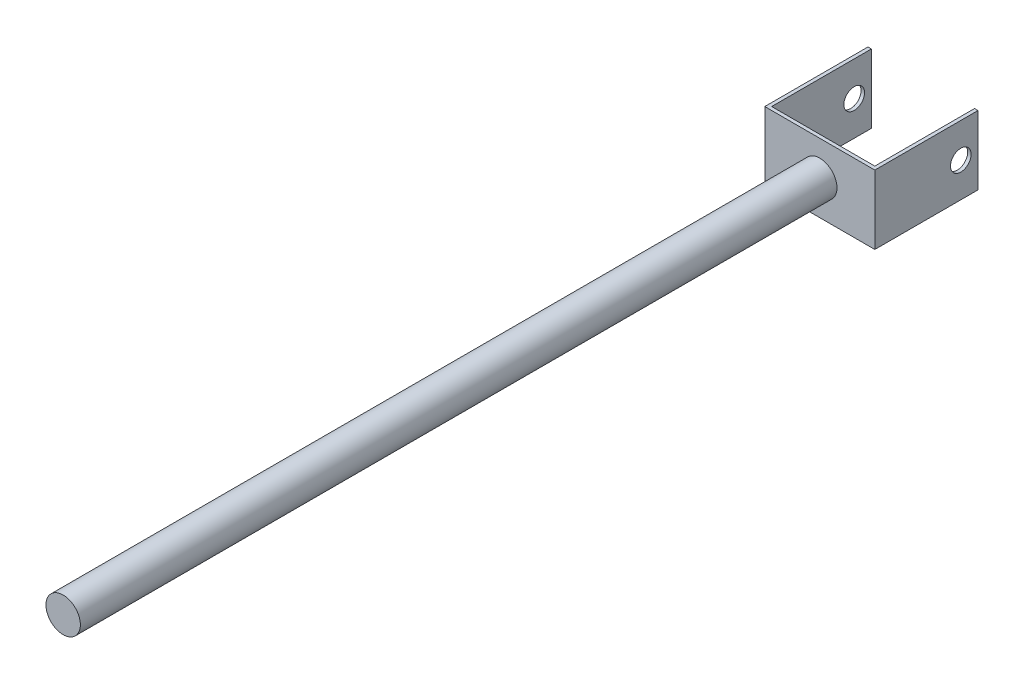
from build123d import *

# Parameters (mm, degrees)
BOSS_EXTRUDE1_DEPTH = 50
SKETCH2_R           = 25
BOSS_EXTRUDE2_DEPTH = 1100
SKETCH3_R           = 15
CUT_EXTRUDE1_DEPTH  = 161


with BuildPart() as part:
    # Sketch1 → Boss-Extrude1 (new body, symmetric)
    with BuildSketch(Plane(origin=(0, 0, 0), x_dir=(1, 0, 0), z_dir=(0, 1, 0))):
        Polygon((0, 0), (-80, 0), (-80, 150), (-75, 150), (-75, 5), (75, 5), (75, 150), (80, 150), (80, 0), align=None)
    extrude(amount=BOSS_EXTRUDE1_DEPTH, both=True)

    # Sketch2 → Boss-Extrude2 (add)
    with BuildSketch(Plane.XY):
        Circle(SKETCH2_R)
    extrude(amount=BOSS_EXTRUDE2_DEPTH)

    # Sketch3 → Cut-Extrude1 (cut, through all)
    with BuildSketch(Plane(origin=(80, 0, 0), x_dir=(0, 0, -1), z_dir=(1, 0, 0))):
        with Locations((125, 0)):
            Circle(SKETCH3_R)
    extrude(amount=-CUT_EXTRUDE1_DEPTH, mode=Mode.SUBTRACT)


solid = part.part
